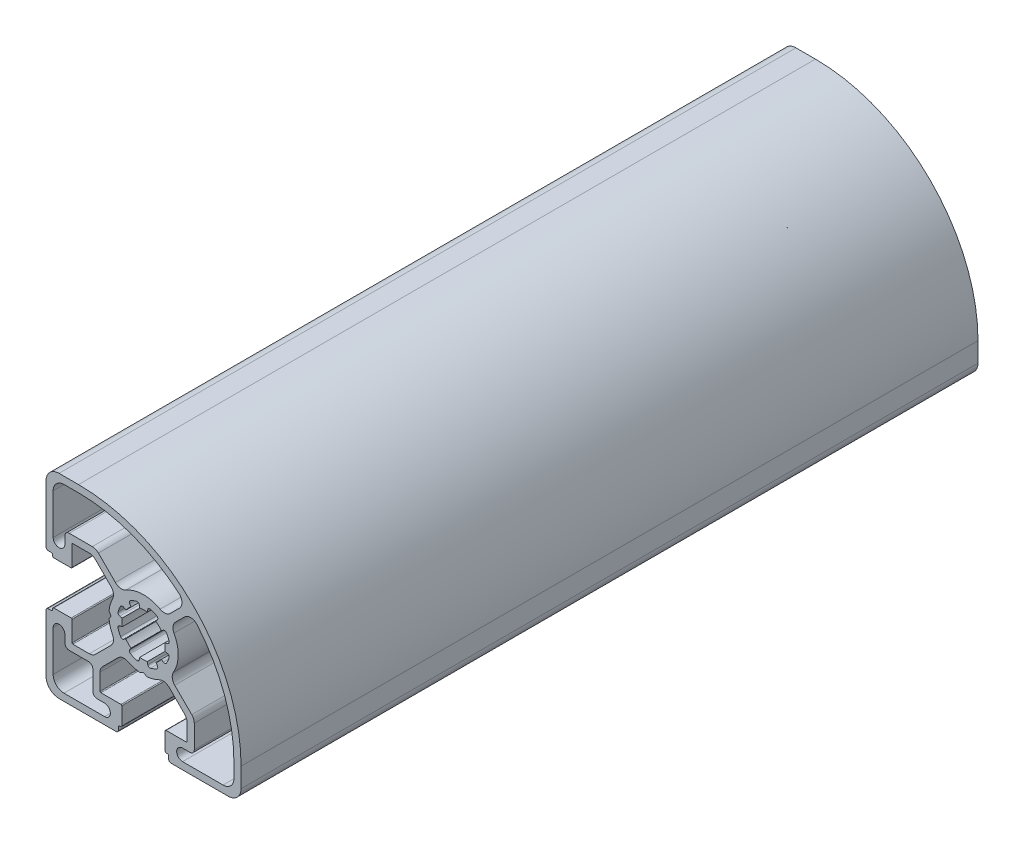
from build123d import *

# Parameters (mm, degrees)
EXTRUDE1_DEPTH = 170


with BuildPart() as part:
    # Sketch5 → Extrude1 (new body)
    with BuildSketch(Plane.XY):
        with BuildLine():
            Line((-22.5000005, 19.5), (-22.5000005, 6.29999))
            ThreePointArc((-22.5000005, 6.29999), (-22.353553891, 5.946436609), (-22.0000005, 5.79999))
            Line((-22.0000005, 5.79999), (-21.299999, 5.79999))
            ThreePointArc((-21.299999, 5.79999), (-21.087866964, 5.712122033), (-20.999999, 5.499989995))
            Line((-20.999999, 5.499989995), (-20.999999, 5.3))
            ThreePointArc((-20.999999, 5.3), (-20.912131034, 5.087867966), (-20.699999, 5))
            Line((-20.699999, 5), (-16.699999, 5))
            ThreePointArc((-16.699999, 5), (-16.558577644, 5.058578644), (-16.499999, 5.2))
            Line((-16.499999, 5.2), (-16.499999, 9.85))
            ThreePointArc((-16.499999, 9.85), (-16.441420355, 9.991421357), (-16.299998997, 10.05))
            Line((-16.299998997, 10.05), (-12.504772, 10.05))
            ThreePointArc((-12.504772, 10.05), (-11.739405151, 9.897759072), (-11.090558462, 9.464213587))
            Line((-11.090558462, 9.464213587), (-7.524263447, 5.897918571))
            ThreePointArc((-7.524263447, 5.897918571), (-6.964095243, 4.802792212), (-7.150781445, 3.586963926))
            ThreePointArc((-7.150781445, 3.586963926), (-7.673956844, 2.260613154), (-7.953373881, 0.862455441))
            ThreePointArc((-7.953373881, 0.862455441), (-7.950237012, 0.799627854), (-7.927742032, 0.740881607))
            Line((-7.927742032, 0.740881607), (-7.557731456, 0.100003005))
            ThreePointArc((-7.557731456, 0.100003005), (-7.530935785, 0), (-7.557731456, -0.100003005))
            Line((-7.557731456, -0.100003005), (-7.927746957, -0.740890137))
            ThreePointArc((-7.927746957, -0.740890137), (-7.95023852, -0.799627407), (-7.95337497, -0.862445398))
            ThreePointArc((-7.95337497, -0.862445398), (-7.673958272, -2.260608308), (-7.150781445, -3.586963926))
            ThreePointArc((-7.150781445, -3.586963926), (-6.964095243, -4.802792212), (-7.524263447, -5.897918571))
            Line((-7.524263447, -5.897918571), (-11.090558462, -9.464213587))
            ThreePointArc((-11.090558462, -9.464213587), (-11.739405151, -9.897759072), (-12.504772, -10.05))
            Line((-12.504772, -10.05), (-16.299999, -10.05))
            ThreePointArc((-16.299999, -10.05), (-16.441420356, -9.991421356), (-16.499999, -9.85))
            Line((-16.499999, -9.85), (-16.499999, -5.2))
            ThreePointArc((-16.499999, -5.2), (-16.558577644, -5.058578644), (-16.699999, -5))
            Line((-16.699999, -5), (-20.699999, -5))
            ThreePointArc((-20.699999, -5), (-20.912131034, -5.087867966), (-20.999999, -5.3))
            Line((-20.999999, -5.3), (-20.999999, -5.49999))
            ThreePointArc((-20.999999, -5.49999), (-21.087866966, -5.712122034), (-21.299999, -5.79999))
            Line((-21.299999, -5.79999), (-22.0000005, -5.79999))
            ThreePointArc((-22.0000005, -5.79999), (-22.353553891, -5.946436609), (-22.5000005, -6.29999))
            Line((-22.5000005, -6.29999), (-22.5000005, -19.5))
            ThreePointArc((-22.5000005, -19.5), (-21.621320844, -21.621320344), (-19.5000005, -22.5))
            Line((-19.5000005, -22.5), (-6.299990052, -22.5))
            ThreePointArc((-6.299990052, -22.5), (-5.946436662, -22.353553391), (-5.799990052, -22))
            Line((-5.799990052, -22), (-5.799990052, -21.3))
            ThreePointArc((-5.799990052, -21.3), (-5.712122087, -21.087867966), (-5.499990052, -21))
            Line((-5.499990052, -21), (-5.300000052, -21))
            ThreePointArc((-5.300000052, -21), (-5.087868018, -20.912132034), (-5.000000052, -20.7))
            Line((-5.000000052, -20.7), (-5.000000052, -16.710063567))
            ThreePointArc((-5.000000052, -16.710063567), (-5.058578696, -16.568642211), (-5.200000052, -16.510063567))
            Line((-5.200000052, -16.510063567), (-9.839936373, -16.510063567))
            ThreePointArc((-9.839936373, -16.510063567), (-9.981357729, -16.451484923), (-10.039936373, -16.310063567))
            Line((-10.039936373, -16.310063567), (-10.039936373, -12.515324723))
            ThreePointArc((-10.039936373, -12.515324723), (-9.887695434, -11.749957847), (-9.454149919, -11.101111144))
            Line((-9.454149919, -11.101111144), (-5.88761152, -7.534572827))
            ThreePointArc((-5.88761152, -7.534572827), (-4.793850301, -6.974625758), (-3.579130007, -7.159852465))
            ThreePointArc((-3.579130007, -7.159852465), (-2.256588376, -7.679939311), (-0.862918903, -7.957953876))
            ThreePointArc((-0.862918903, -7.957953876), (-0.80010208, -7.95481736), (-0.741365901, -7.9323262))
            Line((-0.741365901, -7.9323262), (-0.13675459, -7.583255048))
            ThreePointArc((-0.13675459, -7.583255048), (-0.036754743, -7.556460317), (0.063245047, -7.58325526))
            Line((0.063245047, -7.58325526), (0.740651031, -7.974356184))
            ThreePointArc((0.740651031, -7.974356184), (0.799325747, -7.996835135), (0.862079305, -8))
            ThreePointArc((0.862079305, -8), (2.271113663, -7.71914655), (3.607736363, -7.19217763))
            ThreePointArc((3.607736363, -7.19217763), (4.823568508, -7.005490071), (5.918698566, -7.565659872))
            Line((5.918698566, -7.565659872), (9.454149919, -11.101111144))
            ThreePointArc((9.454149919, -11.101111144), (9.887695434, -11.749957847), (10.039936373, -12.515324723))
            Line((10.039936373, -12.515324723), (10.039936373, -16.310063567))
            ThreePointArc((10.039936373, -16.310063567), (9.981357729, -16.451484923), (9.839936373, -16.510063567))
            Line((9.839936373, -16.510063567), (5.200000052, -16.510063567))
            ThreePointArc((5.200000052, -16.510063567), (5.058578696, -16.568642211), (5.000000052, -16.710063567))
            Line((5.000000052, -16.710063567), (5.000000052, -20.710316899))
            ThreePointArc((5.000000052, -20.710316899), (5.087868018, -20.922448933), (5.300000052, -21.010316899))
            Line((5.300000052, -21.010316899), (5.499990052, -21.010316899))
            ThreePointArc((5.499990052, -21.010316899), (5.712122087, -21.098184865), (5.799990052, -21.310316899))
            Line((5.799990052, -21.310316899), (5.799990052, -21.999999091))
            ThreePointArc((5.799990052, -21.999999091), (5.946436928, -22.353553124), (6.299990962, -22.5))
            Line((6.299990962, -22.5), (19.5000005, -22.5))
            ThreePointArc((19.5000005, -22.5), (21.621320844, -21.621320344), (22.5000005, -19.5))
            Line((22.5000005, -19.5), (22.5000005, -15))
            ThreePointArc((22.5000005, -15), (11.516504794, 11.516504294), (-14.9999995, 22.5))
            Line((-14.9999995, 22.5), (-19.5000005, 22.5))
            ThreePointArc((-19.5000005, 22.5), (-21.621320844, 21.621320344), (-22.5000005, 19.5))
        make_face()
        with BuildLine():
            Line((9.435422541, 8.268705841), (7.366406889, 6.199690189))
            ThreePointArc((7.366406889, 6.199690189), (6.801091464, 5.070897284), (7.024497094, 3.828381739))
            ThreePointArc((7.024497094, 3.828381739), (7.998867258, -0.134865674), (6.891443474, -4.0630128))
            ThreePointArc((6.891443474, -4.0630128), (6.630245567, -5.330766879), (7.200087974, -6.492964961))
            Line((7.200087974, -6.492964961), (11.114215721, -10.407093515))
            ThreePointArc((11.114215721, -10.407093515), (11.547761108, -11.055940148), (11.700002, -11.8213069))
            Line((11.700002, -11.8213069), (11.700002, -17.150002))
            ThreePointArc((11.700002, -17.150002), (11.407108781, -17.857108781), (10.700002, -18.150002))
            Line((10.700002, -18.150002), (8.999997019, -18.150002))
            ThreePointArc((8.999997019, -18.150002), (7.649997019, -19.500002), (8.999997019, -20.850002))
            Line((8.999997019, -20.850002), (18.3500005, -20.850002))
            ThreePointArc((18.3500005, -20.850002), (20.117767453, -20.117768953), (20.8500005, -18.350002))
            Line((20.8500005, -18.350002), (20.8500005, -15))
            ThreePointArc((20.8500005, -15), (18.665159213, -2.676056278), (12.37694115, 8.145747356))
            ThreePointArc((12.37694115, 8.145747356), (10.933165269, 8.852747265), (9.435422541, 8.268705841))
        make_face(mode=Mode.SUBTRACT)
        with BuildLine():
            Line((-6.49297942, 7.200083233), (-10.407112492, 11.114215775))
            ThreePointArc((-10.407112492, 11.114215775), (-11.055959027, 11.547761121), (-11.821325677, 11.700002))
            Line((-11.821325677, 11.700002), (-17.150002, 11.700002))
            ThreePointArc((-17.150002, 11.700002), (-17.857108781, 11.407108781), (-18.150002, 10.700002))
            Line((-18.150002, 10.700002), (-18.150002, 9.000002))
            ThreePointArc((-18.150002, 9.000002), (-19.500002, 7.650002), (-20.850002, 9.000002))
            Line((-20.850002, 9.000002), (-20.850002, 18.349998))
            ThreePointArc((-20.850002, 18.349998), (-20.117768953, 20.117764953), (-18.350002, 20.849998))
            Line((-18.350002, 20.849998), (-14.9999995, 20.849998))
            ThreePointArc((-14.9999995, 20.849998), (-2.676059537, 18.665157959), (8.14574157, 12.376943345))
            ThreePointArc((8.14574157, 12.376943345), (8.852741732, 10.933167277), (8.268700064, 9.435424344))
            Line((8.268700064, 9.435424344), (6.19968069, 7.366405746))
            ThreePointArc((6.19968069, 7.366405746), (5.070888426, 6.801090632), (3.828373494, 7.024495641))
            ThreePointArc((3.828373494, 7.024495641), (-0.134870464, 7.99886249), (-4.063012962, 6.891437575))
            ThreePointArc((-4.063012962, 6.891437575), (-5.330774413, 6.630237598), (-6.49297942, 7.200083233))
        make_face(mode=Mode.SUBTRACT)
        with BuildLine():
            Line((-20.850002, -18.350002), (-20.850002, -9.000002))
            ThreePointArc((-20.850002, -9.000002), (-19.500002, -7.650002), (-18.150002, -9.000002))
            Line((-18.150002, -9.000002), (-18.150002, -10.700002))
            ThreePointArc((-18.150002, -10.700002), (-17.857108781, -11.407108781), (-17.150002, -11.700002))
            Line((-17.150002, -11.700002), (-12.700002, -11.700002))
            ThreePointArc((-12.700002, -11.700002), (-11.992895219, -11.992895219), (-11.700002, -12.700002))
            Line((-11.700002, -12.700002), (-11.700002, -17.150002))
            ThreePointArc((-11.700002, -17.150002), (-11.407108781, -17.857108781), (-10.700002, -18.150002))
            Line((-10.700002, -18.150002), (-9.000002, -18.150002))
            ThreePointArc((-9.000002, -18.150002), (-7.650002, -19.500002), (-9.000002, -20.850002))
            Line((-9.000002, -20.850002), (-18.350002, -20.850002))
            ThreePointArc((-18.350002, -20.850002), (-20.117768953, -20.117768953), (-20.850002, -18.350002))
        make_face(mode=Mode.SUBTRACT)
        with BuildLine():
            Line((-0.868268974, 4.924033813), (-0.968572016, 5.492905266))
            ThreePointArc((-0.968572016, 5.492905266), (-1.19277783, 5.828068218), (-1.591422617, 5.888770642))
            ThreePointArc((-1.591422617, 5.888770642), (-2.334389149, 5.635678568), (-3.038707407, 5.28928189))
            ThreePointArc((-3.038707407, 5.28928189), (-3.277667113, 4.964472304), (-3.199204489, 4.56893896))
            Line((-3.199204489, 4.56893896), (-2.867872407, 4.095767066))
            ThreePointArc((-2.867872407, 4.095767066), (-3.53545954, 3.53560827), (-4.095646419, 2.868044701))
            Line((-4.095646419, 2.868044701), (-4.568771261, 3.199313474))
            ThreePointArc((-4.568771261, 3.199313474), (-4.964289468, 3.27776306), (-5.28908813, 3.038817837))
            ThreePointArc((-5.28908813, 3.038817837), (-5.635542159, 2.334423199), (-5.888668071, 1.591369047))
            ThreePointArc((-5.888668071, 1.591369047), (-5.827965945, 1.19272842), (-5.49280773, 0.968523004))
            Line((-5.49280773, 0.968523004), (-4.924040154, 0.868233012))
            ThreePointArc((-4.924040154, 0.868233012), (-5, 0), (-4.924040154, -0.868233012))
            Line((-4.924040154, -0.868233012), (-5.49280773, -0.968523004))
            ThreePointArc((-5.49280773, -0.968523004), (-5.827965945, -1.19272842), (-5.888668071, -1.591369047))
            ThreePointArc((-5.888668071, -1.591369047), (-5.635542159, -2.334423199), (-5.28908813, -3.038817837))
            ThreePointArc((-5.28908813, -3.038817837), (-4.964289468, -3.27776306), (-4.568771261, -3.199313474))
            Line((-4.568771261, -3.199313474), (-4.095646419, -2.868044701))
            ThreePointArc((-4.095646419, -2.868044701), (-3.53545954, -3.53560827), (-2.867872407, -4.095767066))
            Line((-2.867872407, -4.095767066), (-3.199204489, -4.56893896))
            ThreePointArc((-3.199204489, -4.56893896), (-3.277667113, -4.964472304), (-3.038707407, -5.28928189))
            ThreePointArc((-3.038707407, -5.28928189), (-2.334389149, -5.635678568), (-1.591422617, -5.888770642))
            ThreePointArc((-1.591422617, -5.888770642), (-1.19277783, -5.828068218), (-0.968572016, -5.492905266))
            Line((-0.968572016, -5.492905266), (-0.868268974, -4.924033813))
            ThreePointArc((-0.868268974, -4.924033813), (0, -5), (0.868268974, -4.924033813))
            Line((0.868268974, -4.924033813), (0.968572016, -5.492905266))
            ThreePointArc((0.968572016, -5.492905266), (1.19277783, -5.828068218), (1.591422617, -5.888770642))
            ThreePointArc((1.591422617, -5.888770642), (2.334389149, -5.635678568), (3.038707407, -5.28928189))
            ThreePointArc((3.038707407, -5.28928189), (3.277667113, -4.964472304), (3.199204489, -4.56893896))
            Line((3.199204489, -4.56893896), (2.867872407, -4.095767066))
            ThreePointArc((2.867872407, -4.095767066), (3.53545954, -3.53560827), (4.095646419, -2.868044701))
            Line((4.095646419, -2.868044701), (4.568771261, -3.199313474))
            ThreePointArc((4.568771261, -3.199313474), (4.964289468, -3.27776306), (5.28908813, -3.038817837))
            ThreePointArc((5.28908813, -3.038817837), (5.635542159, -2.334423199), (5.888668071, -1.591369047))
            ThreePointArc((5.888668071, -1.591369047), (5.827965945, -1.19272842), (5.49280773, -0.968523004))
            Line((5.49280773, -0.968523004), (4.924040154, -0.868233012))
            ThreePointArc((4.924040154, -0.868233012), (5, 0), (4.924040154, 0.868233012))
            Line((4.924040154, 0.868233012), (5.49280773, 0.968523004))
            ThreePointArc((5.49280773, 0.968523004), (5.827965945, 1.19272842), (5.888668071, 1.591369047))
            ThreePointArc((5.888668071, 1.591369047), (5.635542159, 2.334423199), (5.28908813, 3.038817837))
            ThreePointArc((5.28908813, 3.038817837), (4.964289468, 3.27776306), (4.568771261, 3.199313474))
            Line((4.568771261, 3.199313474), (4.095646419, 2.868044701))
            ThreePointArc((4.095646419, 2.868044701), (3.53545954, 3.53560827), (2.867872407, 4.095767066))
            Line((2.867872407, 4.095767066), (3.199204489, 4.56893896))
            ThreePointArc((3.199204489, 4.56893896), (3.277667113, 4.964472304), (3.038707407, 5.28928189))
            ThreePointArc((3.038707407, 5.28928189), (2.334389149, 5.635678568), (1.591422617, 5.888770642))
            ThreePointArc((1.591422617, 5.888770642), (1.19277783, 5.828068218), (0.968572016, 5.492905266))
            Line((0.968572016, 5.492905266), (0.868268974, 4.924033813))
            ThreePointArc((0.868268974, 4.924033813), (0, 5), (-0.868268974, 4.924033813))
        make_face(mode=Mode.SUBTRACT)
    extrude(amount=-EXTRUDE1_DEPTH)


solid = part.part
